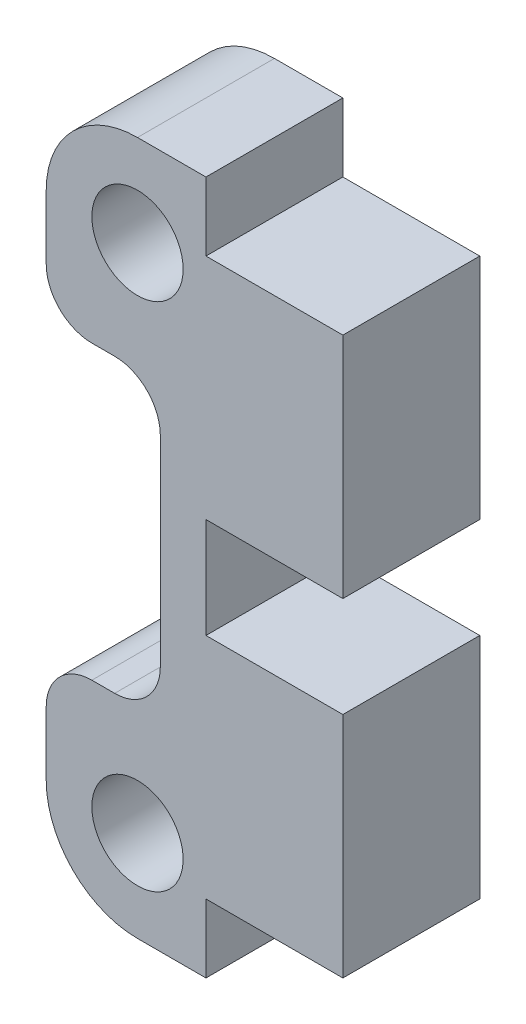
from build123d import *

# Parameters (mm, degrees)
ESQUISSE1_R        = 2
BOSS_EXTRU_1_DEPTH = 6


with BuildPart() as part:
    # Esquisse1 → Boss.-Extru.1 (new body)
    with BuildSketch(Plane.XY):
        with BuildLine():
            Line((-8.999739216, 15.2), (-5.999739216, 15.2))
            Line((-5.999739216, 15.2), (-5.999739216, 12.2))
            Line((-5.999739216, 12.2), (0.000260784, 12.2))
            Line((0.000260784, 12.2), (0, 2.2))
            Line((0, 2.2), (-5.999739216, 2.2))
            Line((-5.999739216, 2.2), (-5.999739216, -2.2))
            Line((-5.999739216, -2.2), (0.000260784, -2.2))
            Line((0.000260784, -2.2), (0.000260784, -12.2))
            Line((0.000260784, -12.2), (-5.999739216, -12.2))
            Line((-5.999739216, -12.2), (-5.999739216, -15.2))
            Line((-5.999739216, -15.2), (-8.999739216, -15.2))
            ThreePointArc((-8.999739216, -15.2), (-11.82816634, -14.028427125), (-12.999739216, -11.2))
            Line((-12.999739216, -11.2), (-12.999739216, -8.39638009))
            ThreePointArc((-12.999739216, -8.39638009), (-12.413952778, -6.982166528), (-10.999739216, -6.39638009))
            Line((-10.999739216, -6.39638009), (-10, -6.39638009))
            ThreePointArc((-10, -6.39638009), (-8.585786438, -5.810593653), (-8, -4.39638009))
            Line((-8, -4.39638009), (-8, 4.39638009))
            ThreePointArc((-8, 4.39638009), (-8.585786438, 5.810593653), (-10, 6.39638009))
            Line((-10, 6.39638009), (-10.999739216, 6.39638009))
            ThreePointArc((-10.999739216, 6.39638009), (-12.413952778, 6.982166528), (-12.999739216, 8.39638009))
            Line((-12.999739216, 8.39638009), (-12.999739216, 11.2))
            ThreePointArc((-12.999739216, 11.2), (-11.82816634, 14.028427125), (-8.999739216, 15.2))
        make_face()
        with Locations((-8.999739216, 11.2)):
            Circle(ESQUISSE1_R, mode=Mode.SUBTRACT)
        with Locations((-8.999739216, -11.2)):
            Circle(ESQUISSE1_R, mode=Mode.SUBTRACT)
    extrude(amount=BOSS_EXTRU_1_DEPTH)


solid = part.part
